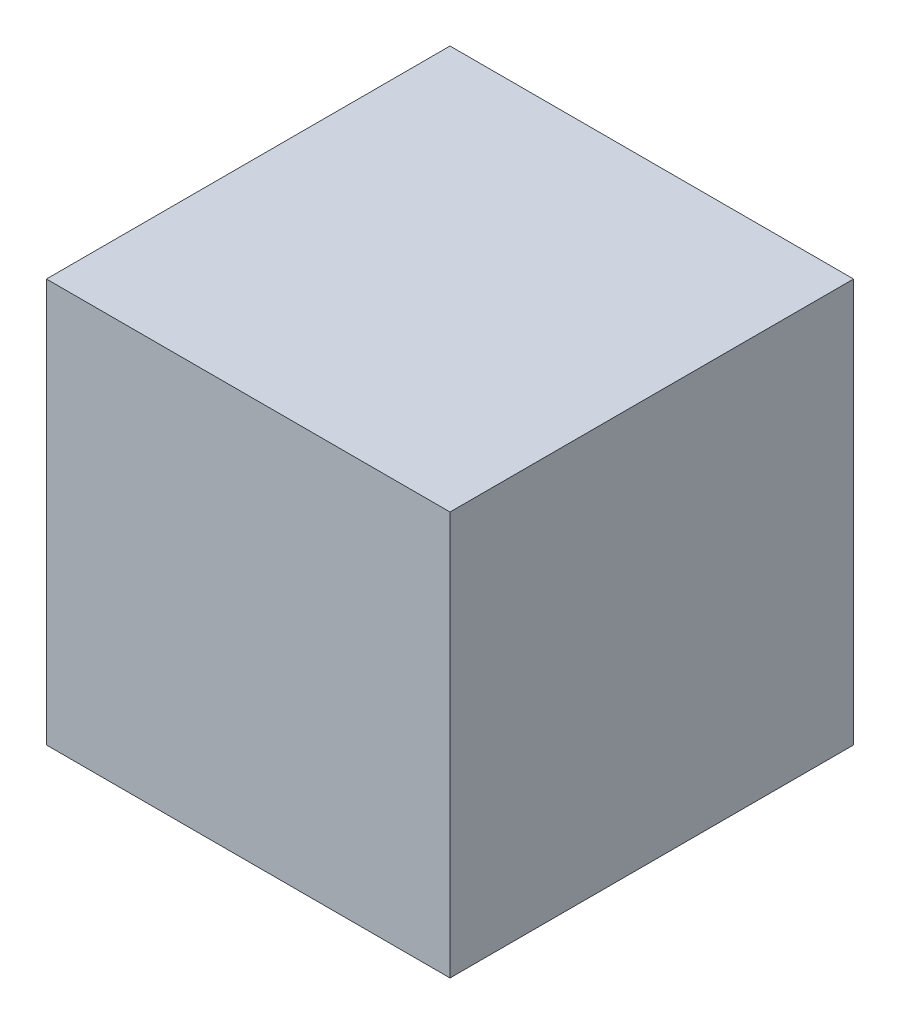
from build123d import *

# Parameters (mm, degrees)
SKETCH1_W           = 381
SKETCH1_H           = 381
BOSS_EXTRUDE1_DEPTH = 381


with BuildPart() as part:
    # Sketch1 → Boss-Extrude1 (new body)
    with BuildSketch(Plane.XY):
        Rectangle(SKETCH1_W, SKETCH1_H)
    extrude(amount=BOSS_EXTRUDE1_DEPTH)


solid = part.part
